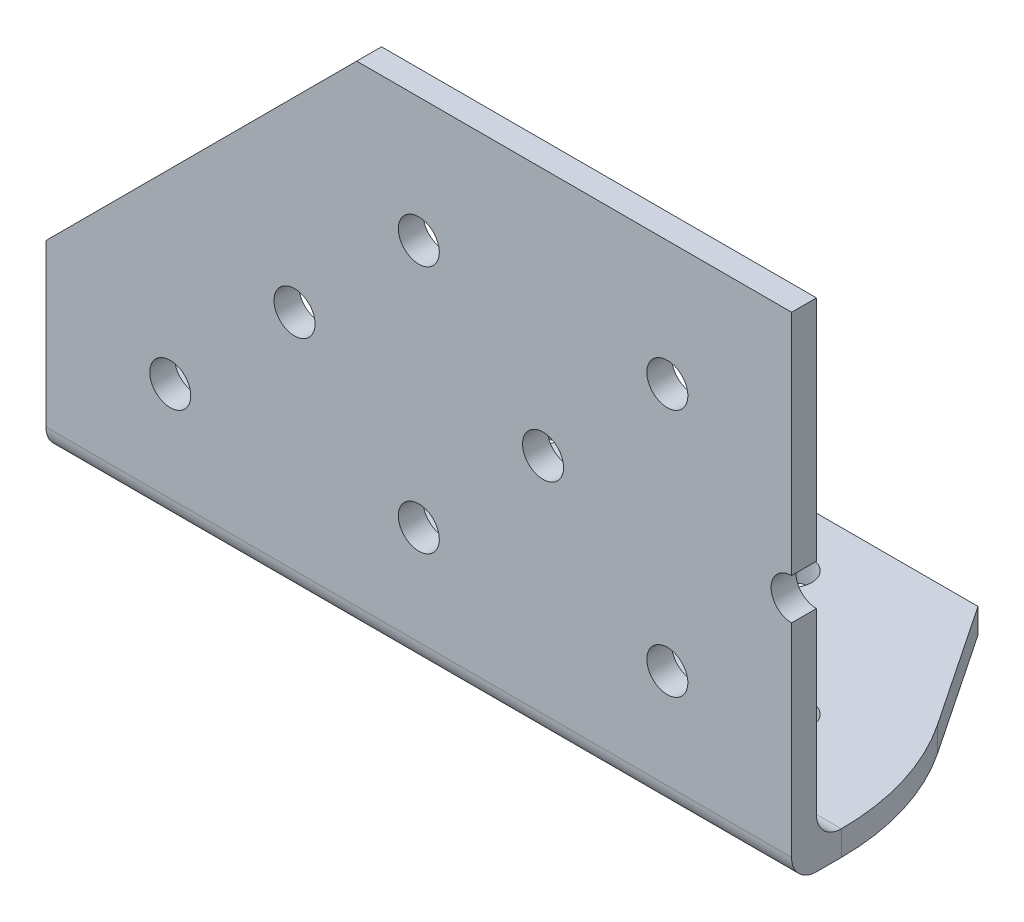
from build123d import *

# Parameters (mm, degrees)
BOSS_EXTRUDE1_DEPTH     = 76.2
SKETCH2_R               = 2.0955
CUT_EXTRUDE1_DEPTH      = 3.54
LPATTERN1_COUNT         = 3
LPATTERN1_PITCH         = 25.4
SKETCH3_R               = 2.0955
CUT_EXTRUDE2_DEPTH      = 3.54
LPATTERN2_COUNT         = 3
LPATTERN2_PITCH         = 25.4
SKETCH4_W               = 76.2
SKETCH4_H               = 19.05
CUT_EXTRUDE3_DEPTH      = 3.54
CUT_EXTRUDE5_DEPTH      = 3.54
CUT_EXTRUDE6_DEPTH      = 49.26
CUT_EXTRUDE6_DEPTH_BACK = 3.54


with BuildPart() as part:
    # Sketch1 → Boss-Extrude1 (new body)
    with BuildSketch(Plane(origin=(0, 0, 0), x_dir=(0, 0, -1), z_dir=(1, 0, 0))):
        with BuildLine():
            Line((0, 2.54), (0, 50.8))
            Line((0, 50.8), (2.54, 50.8))
            Line((2.54, 50.8), (2.54, 5.08))
            ThreePointArc((2.54, 5.08), (3.283948776, 3.283948776), (5.08, 2.54))
            Line((5.08, 2.54), (50.8, 2.54))
            Line((50.8, 2.54), (50.8, 0))
            Line((50.8, 0), (2.54, 0))
            ThreePointArc((2.54, 0), (0.743948776, 0.743948776), (0, 2.54))
        make_face()
    extrude(amount=BOSS_EXTRUDE1_DEPTH)

    # Sketch2 → Cut-Extrude1 (cut, through all)
    with BuildSketch(Plane(origin=(0, 2.54, 0), x_dir=(1, 0, 0), z_dir=(0, 1, 0))):
        with Locations((12.7, 38.0619)):
            Circle(SKETCH2_R)
        with Locations((12.7, 12.6619)):
            Circle(SKETCH2_R)
        with Locations((25.4, 25.3619)):
            Circle(SKETCH2_R)
    cut_extrude1 = extrude(amount=-CUT_EXTRUDE1_DEPTH, mode=Mode.SUBTRACT)

    # LPattern1: Cut-Extrude1 ×3
    with Locations(*[(i * LPATTERN1_PITCH, 0, 0) for i in range(1, LPATTERN1_COUNT)]):
        add(cut_extrude1, mode=Mode.SUBTRACT)

    # Sketch3 → Cut-Extrude2 (cut, through all)
    with BuildSketch(Plane(origin=(0, 0, -2.54), x_dir=(-1, 0, 0), z_dir=(0, 0, -1))):
        with Locations((-12.7, 38.1)):
            Circle(SKETCH3_R)
        with Locations((-12.7, 12.7)):
            Circle(SKETCH3_R)
        with Locations((-25.4, 25.4)):
            Circle(SKETCH3_R)
    cut_extrude2 = extrude(amount=-CUT_EXTRUDE2_DEPTH, mode=Mode.SUBTRACT)

    # LPattern2: Cut-Extrude2 ×3
    with Locations(*[(i * LPATTERN2_PITCH, 0, 0) for i in range(1, LPATTERN2_COUNT)]):
        add(cut_extrude2, mode=Mode.SUBTRACT)

    # Sketch4 → Cut-Extrude3 (cut, through all)
    with BuildSketch(Plane(origin=(0, 2.54, 0), x_dir=(1, 0, 0), z_dir=(0, 1, 0))):
        with Locations((38.1, 41.275)):
            Rectangle(SKETCH4_W, SKETCH4_H)
    extrude(amount=-CUT_EXTRUDE3_DEPTH, mode=Mode.SUBTRACT)

    # Sketch6 → Cut-Extrude5 (cut, through all)
    with BuildSketch(Plane(origin=(0, 0, -2.54), x_dir=(-1, 0, 0), z_dir=(0, 0, -1))):
        Polygon((0, 19.05), (0, 50.8), (-31.75, 50.8), align=None)
    extrude(amount=-CUT_EXTRUDE5_DEPTH, mode=Mode.SUBTRACT)

    # Sketch7 → Cut-Extrude6 (cut, two sides)
    with BuildSketch(Plane(origin=(0, 2.54, 0), x_dir=(1, 0, 0), z_dir=(0, 1, 0))) as cut_extrude6_sk:
        with BuildLine():
            Line((63.5, 31.75), (71.897549111, 19.224024233))
            ThreePointArc((71.897549111, 19.224024233), (75.100594102, 12.471963629), (76.2, 5.08))
            Line((76.2, 5.08), (76.2, 31.75))
            Line((76.2, 31.75), (63.5, 31.75))
        make_face()
        with BuildLine():
            Line((12.7, 31.75), (4.302450889, 19.224024233))
            ThreePointArc((4.302450889, 19.224024233), (1.099405898, 12.471963629), (0, 5.08))
            Line((0, 5.08), (0, 31.75))
            Line((0, 31.75), (12.7, 31.75))
        make_face()
    extrude(amount=CUT_EXTRUDE6_DEPTH, mode=Mode.SUBTRACT)
    extrude(cut_extrude6_sk.sketch, amount=-CUT_EXTRUDE6_DEPTH_BACK, mode=Mode.SUBTRACT)


solid = part.part
